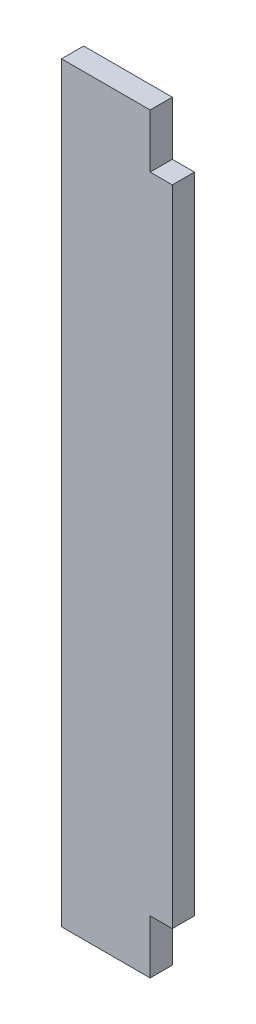
from build123d import *

# Parameters (mm, degrees)
BRACE_THICKNESS_DEPTH = 17.78


with BuildPart() as part:
    # BraceOutline → Brace_Thickness (new body)
    with BuildSketch(Plane.XY):
        Polygon((11403.541666666, -6411.9125), (11474.661666666, -6411.9125), (11474.661666666, -6368.7325), (11492.441666666, -6368.7325), (11492.441666666, -5851.8425), (11474.661666666, -5851.8425), (11474.661666666, -5808.6625), (11403.541666666, -5808.6625), align=None)
    extrude(amount=-BRACE_THICKNESS_DEPTH)


solid = part.part
